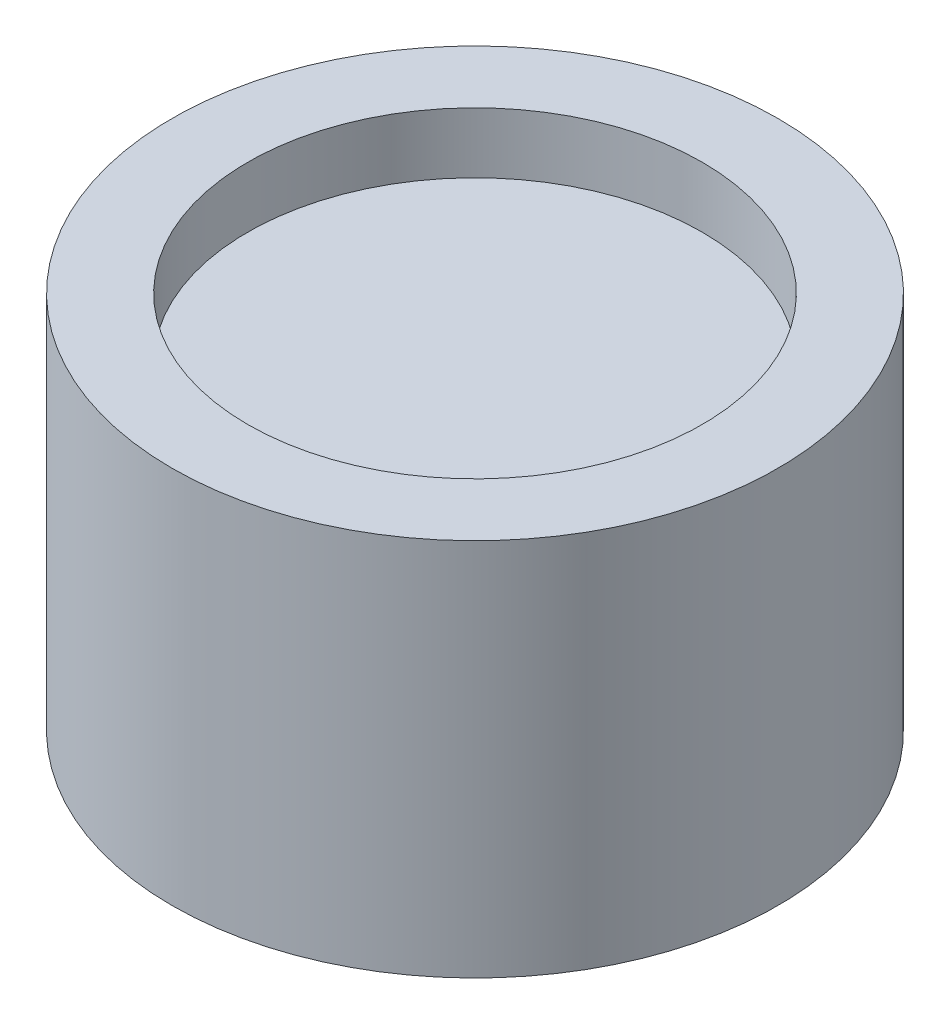
from build123d import *

# Parameters (mm, degrees)
ESBO_O3_R             = 8
CORTE_EXTRUS_O2_DEPTH = 10


with BuildPart() as part:
    # Esboço1 → Revolução1 (revolve)
    with BuildSketch(Plane.XY):
        Polygon((150, 250), (200, 250), (200, 0), (0, 0), (0, 210), (150, 210), align=None)
    revolve(axis=Axis((0, 0, 0), (0, 1, 0)))

    # Esboço3 → Corte-extrusão2 (cut)
    with BuildSketch(Plane.XZ):
        with Locations((-71, 55)):
            Circle(ESBO_O3_R)
        with Locations((71, 55)):
            Circle(ESBO_O3_R)
        with Locations((71, -55)):
            Circle(ESBO_O3_R)
        with Locations((-71, -55)):
            Circle(ESBO_O3_R)
    extrude(amount=-CORTE_EXTRUS_O2_DEPTH, mode=Mode.SUBTRACT)


solid = part.part
